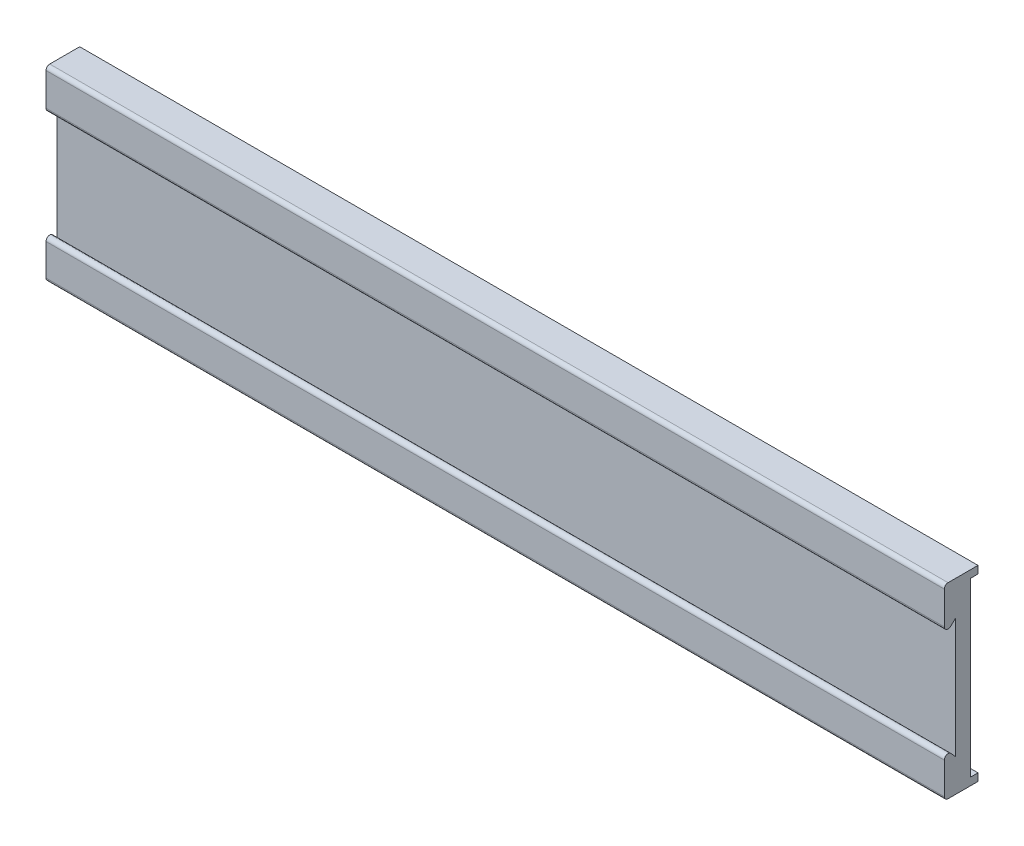
from build123d import *

# Parameters (mm, degrees)
SKETCH1_W           = 120
SKETCH1_H           = 25
BOSS_EXTRUDE1_DEPTH = 3.5
SKETCH1_3_W         = 120
SKETCH1_3_H         = 1
BOSS_EXTRUDE2_DEPTH = 1
CUT_EXTRUDE1_DEPTH  = 123.626465333
FILLET1_R           = 0.5
FILLET2_R           = 0.5


with BuildPart() as part:
    # Sketch1 → Boss-Extrude1 (new body)
    with BuildSketch(Plane.XY):
        with Locations((60, 12.5)):
            Rectangle(SKETCH1_W, SKETCH1_H)
    extrude(amount=BOSS_EXTRUDE1_DEPTH)

    # Sketch1_3 → Boss-Extrude2 (add)
    with BuildSketch(Plane.XY):
        with Locations((60, 24.5)):
            Rectangle(SKETCH1_3_W, SKETCH1_3_H)
        with Locations((60, 0.5)):
            Rectangle(SKETCH1_3_W, SKETCH1_3_H)
    extrude(amount=-BOSS_EXTRUDE2_DEPTH)

    # Sketch3 → Cut-Extrude1 (cut, through all)
    with BuildSketch(Plane(origin=(120, 0, 0), x_dir=(0, 0, -1), z_dir=(1, 0, 0))):
        Polygon((-2, 20.384047046), (-3.5, 19), (-3.5, 6), (-2, 4.374332717), align=None)
    extrude(amount=-CUT_EXTRUDE1_DEPTH, mode=Mode.SUBTRACT)

    # Fillet1
    fillet1_edges = [part.edges().sort_by_distance(p)[0] for p in [
        (60, 19, 3.5),
        (60, 6, 3.5),
    ]]
    fillet(fillet1_edges, radius=FILLET1_R)

    # Fillet2
    fillet2_edges = [part.edges().sort_by_distance(p)[0] for p in [
        (60, 0, 3.5),
        (60, 25, 3.5),
    ]]
    fillet(fillet2_edges, radius=FILLET2_R)


solid = part.part
